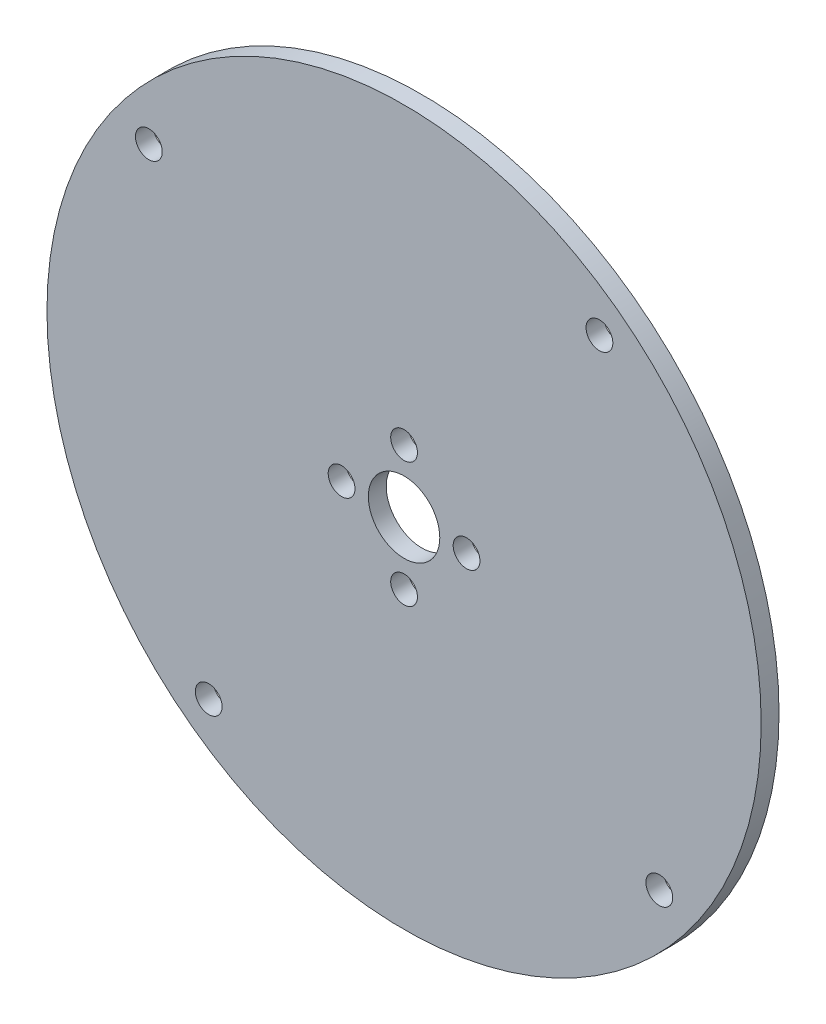
from build123d import *

# Parameters (mm, degrees)
SKETCH_3_R      = 40
SKETCH_3_R_2    = 4
SKETCH_3_R_3    = 1.5
EXTRUDE_1_DEPTH = 2


with BuildPart() as part:
    # 草图3 → 凸台-拉伸1 (new body)
    with BuildSketch(Plane.XY):
        Circle(SKETCH_3_R)
        Circle(SKETCH_3_R_2, mode=Mode.SUBTRACT)
        with Locations((0, 7)):
            Circle(SKETCH_3_R_3, mode=Mode.SUBTRACT)
        with Locations((0, -7)):
            Circle(SKETCH_3_R_3, mode=Mode.SUBTRACT)
        with Locations((-7, 0)):
            Circle(SKETCH_3_R_3, mode=Mode.SUBTRACT)
        with Locations((7, 0)):
            Circle(SKETCH_3_R_3, mode=Mode.SUBTRACT)
        with Locations((-28.586016786, 21.882404903)):
            Circle(SKETCH_3_R_3, mode=Mode.SUBTRACT)
        with Locations((21.882404903, 28.586016786)):
            Circle(SKETCH_3_R_3, mode=Mode.SUBTRACT)
        with Locations((-21.882404903, -28.586016786)):
            Circle(SKETCH_3_R_3, mode=Mode.SUBTRACT)
        with Locations((28.586016786, -21.882404903)):
            Circle(SKETCH_3_R_3, mode=Mode.SUBTRACT)
    extrude(amount=EXTRUDE_1_DEPTH)


solid = part.part
